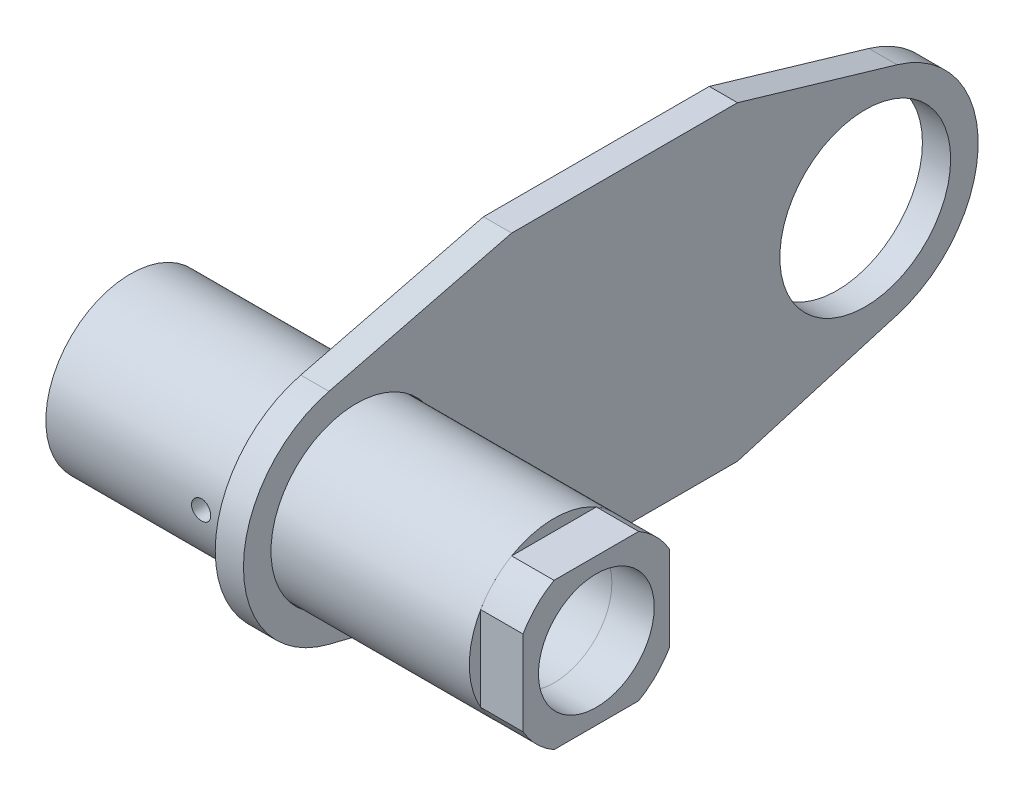
from build123d import *

# Parameters (mm, degrees)
ROND_R                      = 30
ROND_R_2                    = 20.5
EL_MENT_M_CANO_SOUD_1_DEPTH = 150
ESQUISSE2_W                 = 3.4
ESQUISSE2_H                 = 30
ESQUISSE5_R                 = 20.5
BOSS_EXTRU_1_DEPTH          = 15
BOSS_EXTRU_2_START          = -70
ESQUISSE6_R                 = 40
ESQUISSE6_R_2               = 30.25
BOSS_EXTRU_2_DEPTH          = 10
ESQUISSE7_R                 = 40
ESQUISSE7_R_2               = 30.25
BOSS_EXTRU_3_DEPTH          = 10


with BuildPart() as part:
    # rond → Elément mécano-soudé1 (new body)
    with BuildSketch(Plane.YZ.offset(-75)):
        Circle(ROND_R)
        Circle(ROND_R_2, mode=Mode.SUBTRACT)
    extrude(amount=EL_MENT_M_CANO_SOUD_1_DEPTH)

    # Esquisse2 → Trou taraudé M8x1.251 (revolve, cut)
    with BuildSketch(Plane.YZ.offset(-20)):
        with Locations((1.7, 15)):
            Rectangle(ESQUISSE2_W, ESQUISSE2_H)
    revolve(axis=Axis((-20, 0, -6.35), (0, 0, 1)), mode=Mode.SUBTRACT)


with BuildPart() as body_2:
    # Esquisse5 → Boss.-Extru.1 (new body)
    with BuildSketch(Plane(origin=(75, 0, 0), x_dir=(0, 0, -1), z_dir=(1, 0, 0))):
        with BuildLine():
            Line((15, 25.980762114), (-15, 25.980762114))
            ThreePointArc((-15, 25.980762114), (-21.213203436, 21.213203436), (-25.980762114, 15))
            Line((-25.980762114, 15), (-25.980762114, -15))
            ThreePointArc((-25.980762114, -15), (-21.213203436, -21.213203436), (-15, -25.980762114))
            Line((-15, -25.980762114), (15, -25.980762114))
            ThreePointArc((15, -25.980762114), (21.213203436, -21.213203436), (25.980762114, -15))
            Line((25.980762114, -15), (25.980762114, 15))
            ThreePointArc((25.980762114, 15), (21.213203436, 21.213203436), (15, 25.980762114))
        make_face()
        Circle(ESQUISSE5_R, mode=Mode.SUBTRACT)
    extrude(amount=BOSS_EXTRU_1_DEPTH)


with BuildPart() as body_3:
    # Esquisse6 → Boss.-Extru.2 (new body)
    with BuildSketch(Plane(origin=(75, 0, 0), x_dir=(0, 0, -1), z_dir=(1, 0, 0)).offset(BOSS_EXTRU_2_START)):
        Circle(ESQUISSE6_R)
        Circle(ESQUISSE6_R_2, mode=Mode.SUBTRACT)
    extrude(amount=-BOSS_EXTRU_2_DEPTH)


with BuildPart() as body_4:
    # Esquisse7 → Boss.-Extru.3 (new body)
    with BuildSketch(Plane(origin=(5, 0, 0), x_dir=(0, 0, -1), z_dir=(1, 0, 0))):
        with BuildLine():
            Line((55, 55), (-9.71211648, 38.803025571))
            ThreePointArc((-9.71211648, 38.803025571), (24.612144774, 31.531608421), (40, 0))
            ThreePointArc((40, 0), (24.612144774, -31.531608421), (-9.71211648, -38.803025571))
            Line((-9.71211648, -38.803025571), (55, -55))
            Line((55, -55), (135, -55))
            Line((135, -55), (191.534749126, -38.375179963))
            ThreePointArc((191.534749126, -38.375179963), (140.25, 0), (191.534749126, 38.375179963))
            Line((191.534749126, 38.375179963), (135, 55))
            Line((135, 55), (55, 55))
        make_face()
        with Locations((180.25, 0)):
            Circle(ESQUISSE7_R)
        with Locations((180.25, 0)):
            Circle(ESQUISSE7_R_2, mode=Mode.SUBTRACT)
        Circle(ESQUISSE7_R)
        Circle(ESQUISSE7_R_2, mode=Mode.SUBTRACT)
    extrude(amount=-BOSS_EXTRU_3_DEPTH)


solid = Compound([part.part, body_2.part, body_4.part])
